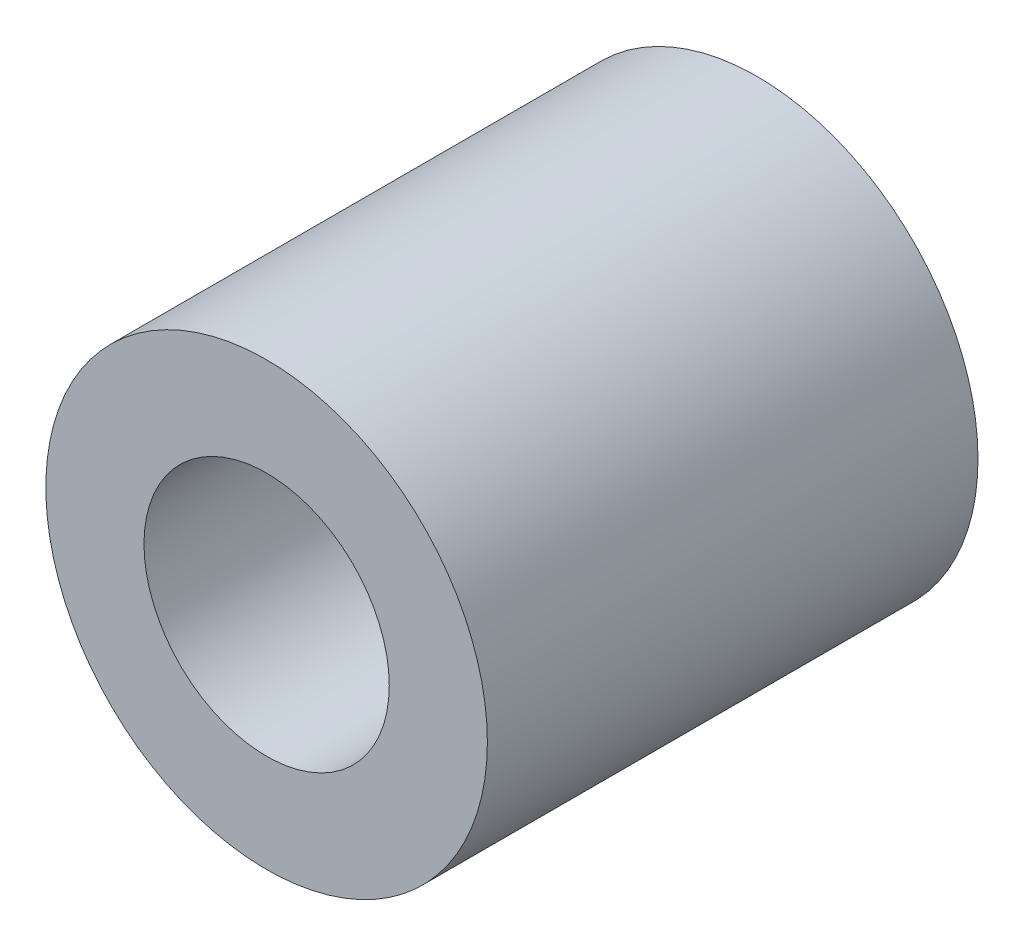
from build123d import *

# Parameters (mm, degrees)
SZKIC1_R                    = 3.15
SZKIC1_R_2                  = 1.75
DODANIE_WYCI_GNI_CIE1_DEPTH = 7


with BuildPart() as part:
    # Szkic1 → Dodanie-wyciągnięcie1 (new body)
    with BuildSketch(Plane.XY):
        Circle(SZKIC1_R)
        Circle(SZKIC1_R_2, mode=Mode.SUBTRACT)
    extrude(amount=DODANIE_WYCI_GNI_CIE1_DEPTH)


solid = part.part
